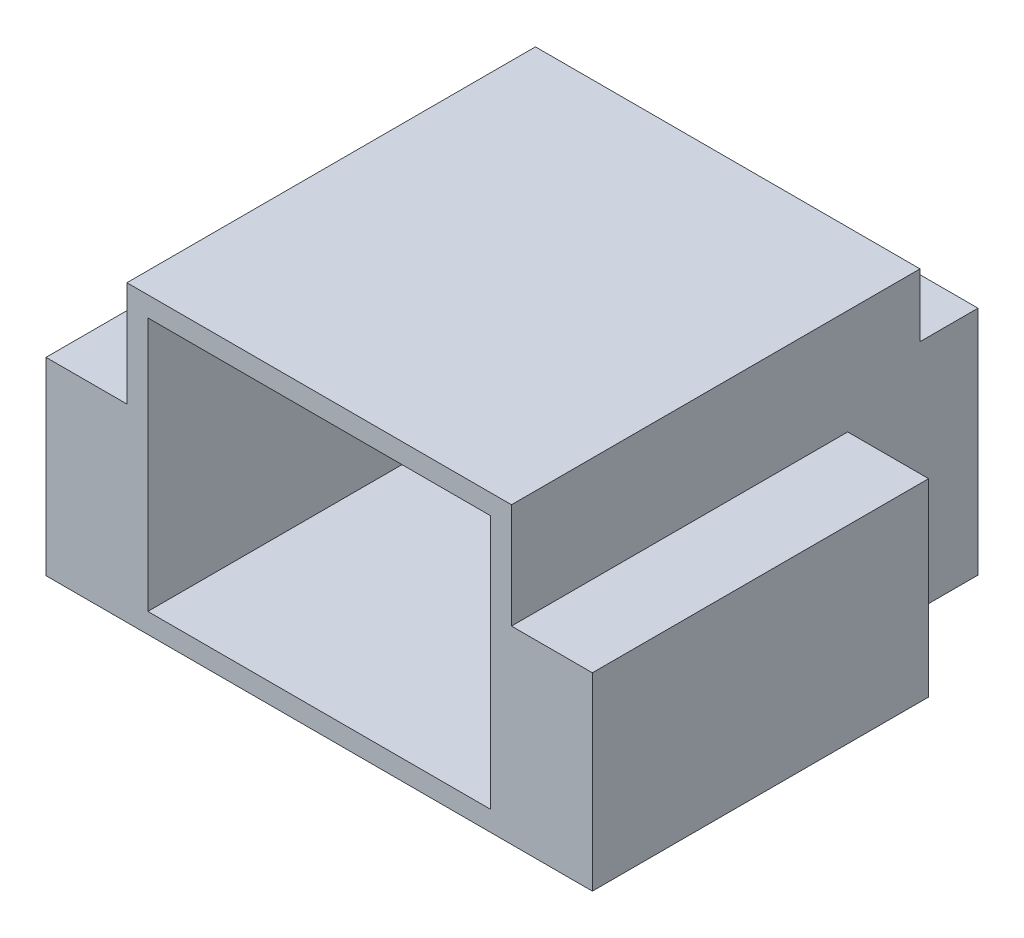
from build123d import *

# Parameters (mm, degrees)
SKETCH1_W           = 9.15
SKETCH1_H           = 3.1
SKETCH1_W_2         = 13
SKETCH1_H_2         = 8
BOSS_EXTRUDE1_DEPTH = 7
SKETCH2_W           = 1.925
SKETCH2_H           = 8
CUT_EXTRUDE1_DEPTH  = 2.5
SKETCH3_W           = 9.15
SKETCH3_H           = 1.379434604
CUT_EXTRUDE2_DEPTH  = 1.5
SKETCH4_W           = 8.155225922
SKETCH4_H           = 6.048851008
CUT_EXTRUDE3_DEPTH  = 8


with BuildPart() as part:
    # Sketch1 → Boss-Extrude1 (new body)
    with BuildSketch(Plane(origin=(0, 0, 0), x_dir=(1, 0, 0), z_dir=(0, 1, 0))):
        with Locations((0, 5.55)):
            Rectangle(SKETCH1_W, SKETCH1_H)
        Rectangle(SKETCH1_W_2, SKETCH1_H_2)
    extrude(amount=BOSS_EXTRUDE1_DEPTH)

    # Sketch2 → Cut-Extrude1 (cut)
    with BuildSketch(Plane(origin=(0, 7, 0), x_dir=(1, 0, 0), z_dir=(0, 1, 0))):
        with Locations((-5.5375, 0)):
            Rectangle(SKETCH2_W, SKETCH2_H)
        with Locations((5.5375, 0)):
            Rectangle(SKETCH2_W, SKETCH2_H)
    extrude(amount=-CUT_EXTRUDE1_DEPTH, mode=Mode.SUBTRACT)

    # Sketch3 → Cut-Extrude2 (cut)
    with BuildSketch(Plane(origin=(0, 7, 0), x_dir=(1, 0, 0), z_dir=(0, 1, 0))):
        with Locations((0, 6.410282698)):
            Rectangle(SKETCH3_W, SKETCH3_H)
    extrude(amount=-CUT_EXTRUDE2_DEPTH, mode=Mode.SUBTRACT)

    # Sketch4 → Cut-Extrude3 (cut)
    with BuildSketch(Plane.XY.offset(4)):
        with Locations((0, 3.5)):
            Rectangle(SKETCH4_W, SKETCH4_H)
    extrude(amount=-CUT_EXTRUDE3_DEPTH, mode=Mode.SUBTRACT)


solid = part.part
